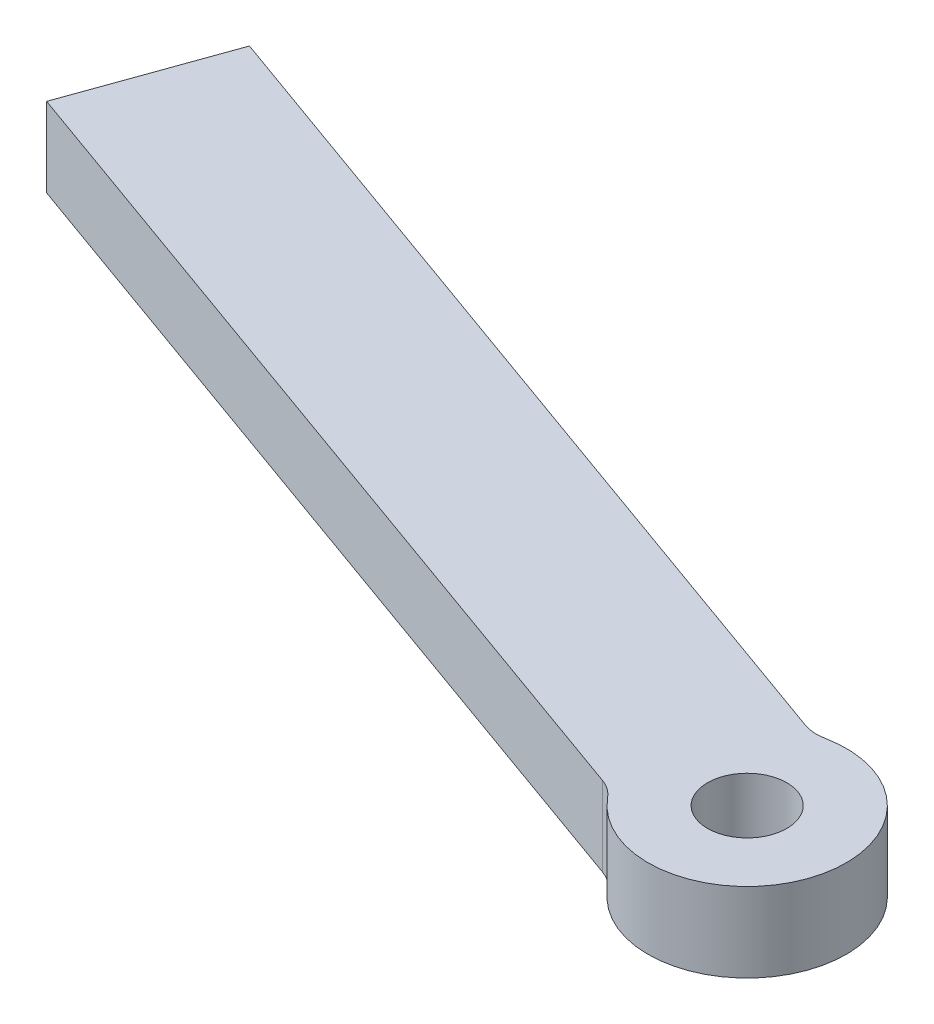
from build123d import *

# Parameters (mm, degrees)
SKETCH1_R           = 1
BOSS_EXTRUDE1_DEPTH = 2


with BuildPart() as part:
    # Sketch1 → Boss-Extrude1 (new body)
    with BuildSketch(Plane(origin=(0, 0, 0), x_dir=(1, 0, 0), z_dir=(0, 1, 0))):
        with BuildLine():
            Line((-1.022874436, 2.490728385), (-22.861764958, 10.312114381))
            Line((-22.861764958, 10.312114381), (-24.21044114, 6.546337894))
            Line((-24.21044114, 6.546337894), (-2.371550618, -1.275048103))
            ThreePointArc((-2.371550618, -1.275048103), (-2.132203917, -1.399406187), (-1.93479976, -1.583208732))
            ThreePointArc((-1.93479976, -1.583208732), (2.353610305, -0.842922614), (-0.489789565, 2.451551791))
            ThreePointArc((-0.489789565, 2.451551791), (-0.758998088, 2.434862033), (-1.022874436, 2.490728385))
        make_face()
        Circle(SKETCH1_R, mode=Mode.SUBTRACT)
    extrude(amount=BOSS_EXTRUDE1_DEPTH)


solid = part.part
